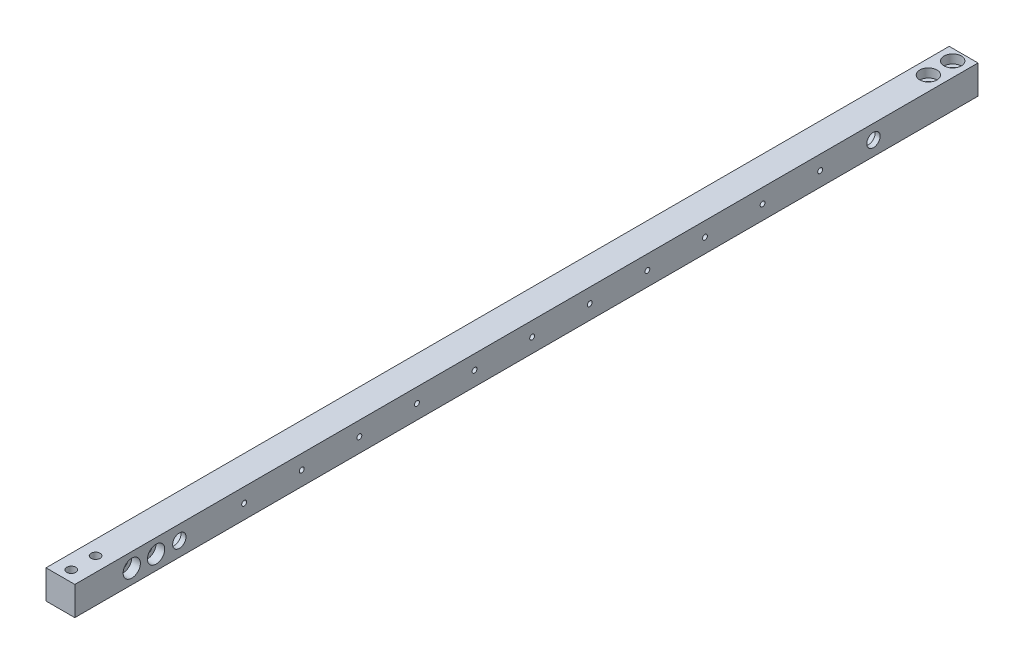
from build123d import *

# Parameters (mm, degrees)
SKETCH1_W                                       = 15.875
SKETCH1_H                                       = 15.875
BOSS_EXTRUDE1_DEPTH                             = 497.84
SKETCH8_R                                       = 6.8199
CUT_EXTRUDE1_DEPTH                              = 13.08608
L_0_29_DIAMETER_HOLE1_D                         = 7.366
L_0_29_DIAMETER_HOLE1_DEPTH                     = 50.8
L_0_29_DIAMETER_HOLE1_TIP                       = 2.21296966
TAP_DRILL_FOR_6_32_TAP1_D                       = 2.7051
CBORE_FOR_10_SOCKET_HEAD_CAP_SCREW3_D           = 4.9784
CBORE_FOR_10_SOCKET_HEAD_CAP_SCREW3_DEPTH       = 25.4
CBORE_FOR_10_SOCKET_HEAD_CAP_SCREW3_CBORE_D     = 9.525
CBORE_FOR_10_SOCKET_HEAD_CAP_SCREW3_CBORE_DEPTH = 4.826
CBORE_FOR_10_SOCKET_HEAD_CAP_SCREW3_TIP         = 1.495662253
CBORE_FOR_10_SOCKET_HEAD_CAP_SCREW2_D           = 4.9784
CBORE_FOR_10_SOCKET_HEAD_CAP_SCREW2_DEPTH       = 25.4
CBORE_FOR_10_SOCKET_HEAD_CAP_SCREW2_CBORE_D     = 9.525
CBORE_FOR_10_SOCKET_HEAD_CAP_SCREW2_CBORE_DEPTH = 4.826
CBORE_FOR_10_SOCKET_HEAD_CAP_SCREW2_TIP         = 1.495662253
CBORE_FOR_10_SOCKET_HEAD_CAP_SCREW1_D           = 4.9784
CBORE_FOR_10_SOCKET_HEAD_CAP_SCREW1_DEPTH       = 25.4
CBORE_FOR_10_SOCKET_HEAD_CAP_SCREW1_CBORE_D     = 9.525
CBORE_FOR_10_SOCKET_HEAD_CAP_SCREW1_CBORE_DEPTH = 4.826
CBORE_FOR_10_SOCKET_HEAD_CAP_SCREW1_TIP         = 1.495662253


with BuildPart() as part:
    # Sketch1 → Boss-Extrude1 (new body)
    with BuildSketch(Plane.XY):
        with Locations((7.9375, 7.9375)):
            Rectangle(SKETCH1_W, SKETCH1_H)
    extrude(amount=BOSS_EXTRUDE1_DEPTH)

    # Sketch8 → Cut-Extrude1 (cut)
    with BuildSketch(Plane.ZY):
        with Locations((440.2201, 7.9375)):
            Circle(SKETCH8_R)
        with Locations((57.6199, 7.9375)):
            Circle(SKETCH8_R)
    extrude(amount=-CUT_EXTRUDE1_DEPTH, mode=Mode.SUBTRACT)

    # L (0.29) Diameter Hole1
    with Locations(Plane.ZY.offset(-13.08608)):
        with Locations((57.6199, 7.9375), (440.2201, 7.9375)):
            Hole(L_0_29_DIAMETER_HOLE1_D / 2, depth=L_0_29_DIAMETER_HOLE1_DEPTH)
            with Locations((0, 0, -(L_0_29_DIAMETER_HOLE1_DEPTH + L_0_29_DIAMETER_HOLE1_TIP / 2))):  # 118° drill point
                Cone(0, L_0_29_DIAMETER_HOLE1_D / 2, L_0_29_DIAMETER_HOLE1_TIP, mode=Mode.SUBTRACT)

    # Tap Drill for #6-32 Tap1 (through all)
    with Locations(Plane(origin=(-468.3125, 1840.244207037, -1707.973131805), x_dir=(0, 0, -1), z_dir=(-1, 0, 0))):
        with Locations((-2112.468131805, 1832.306707037), (-2080.718131805, 1832.306707037), (-2048.968131805, 1832.306707037), (-2017.218131805, 1832.306707037), (-1985.468131805, 1832.306707037), (-1953.718131805, 1832.306707037), (-1921.968131805, 1832.306707037), (-1890.218131805, 1832.306707037), (-1858.468131805, 1832.306707037), (-1826.718131805, 1832.306707037), (-1794.968131805, 1832.306707037)):
            Hole(TAP_DRILL_FOR_6_32_TAP1_D / 2)

    # CBORE for #10 Socket Head Cap Screw3
    with Locations(Plane(origin=(412.874136144, 0, -1707.973131805), x_dir=(-1, 0, 0), z_dir=(0, -1, 0))):
        with Locations((871.661636144, -2186.413131805), (871.661636144, -2199.813131805), (404.936636144, -2186.413131805), (404.936636144, -2199.813131805)):
            CounterBoreHole(CBORE_FOR_10_SOCKET_HEAD_CAP_SCREW3_D / 2, CBORE_FOR_10_SOCKET_HEAD_CAP_SCREW3_CBORE_D / 2, CBORE_FOR_10_SOCKET_HEAD_CAP_SCREW3_CBORE_DEPTH, depth=CBORE_FOR_10_SOCKET_HEAD_CAP_SCREW3_DEPTH)
            with Locations((0, 0, -(CBORE_FOR_10_SOCKET_HEAD_CAP_SCREW3_DEPTH + CBORE_FOR_10_SOCKET_HEAD_CAP_SCREW3_TIP / 2))):  # 118° drill point
                Cone(0, CBORE_FOR_10_SOCKET_HEAD_CAP_SCREW3_D / 2, CBORE_FOR_10_SOCKET_HEAD_CAP_SCREW3_TIP, mode=Mode.SUBTRACT)

    # CBORE for #10 Socket Head Cap Screw2
    with Locations(Plane(origin=(412.874136144, 15.875, -1707.973131805), x_dir=(1, 0, 0), z_dir=(0, 1, 0))):
        with Locations((-404.936636144, -1727.373131805), (-404.936636144, -1713.973131805), (-871.661636144, -1727.373131805), (-871.661636144, -1713.973131805)):
            CounterBoreHole(CBORE_FOR_10_SOCKET_HEAD_CAP_SCREW2_D / 2, CBORE_FOR_10_SOCKET_HEAD_CAP_SCREW2_CBORE_D / 2, CBORE_FOR_10_SOCKET_HEAD_CAP_SCREW2_CBORE_DEPTH, depth=CBORE_FOR_10_SOCKET_HEAD_CAP_SCREW2_DEPTH)
            with Locations((0, 0, -(CBORE_FOR_10_SOCKET_HEAD_CAP_SCREW2_DEPTH + CBORE_FOR_10_SOCKET_HEAD_CAP_SCREW2_TIP / 2))):  # 118° drill point
                Cone(0, CBORE_FOR_10_SOCKET_HEAD_CAP_SCREW2_D / 2, CBORE_FOR_10_SOCKET_HEAD_CAP_SCREW2_TIP, mode=Mode.SUBTRACT)

    # CBORE for #10 Socket Head Cap Screw1
    with Locations(Plane(origin=(15.875, 1702.05448625, -1707.973131805), x_dir=(0, 0, 1), z_dir=(1, 0, 0))):
        with Locations((2161.013131805, 1694.11698625), (2174.413131805, 1694.11698625)):
            CounterBoreHole(CBORE_FOR_10_SOCKET_HEAD_CAP_SCREW1_D / 2, CBORE_FOR_10_SOCKET_HEAD_CAP_SCREW1_CBORE_D / 2, CBORE_FOR_10_SOCKET_HEAD_CAP_SCREW1_CBORE_DEPTH, depth=CBORE_FOR_10_SOCKET_HEAD_CAP_SCREW1_DEPTH)
            with Locations((0, 0, -(CBORE_FOR_10_SOCKET_HEAD_CAP_SCREW1_DEPTH + CBORE_FOR_10_SOCKET_HEAD_CAP_SCREW1_TIP / 2))):  # 118° drill point
                Cone(0, CBORE_FOR_10_SOCKET_HEAD_CAP_SCREW1_D / 2, CBORE_FOR_10_SOCKET_HEAD_CAP_SCREW1_TIP, mode=Mode.SUBTRACT)


solid = part.part
